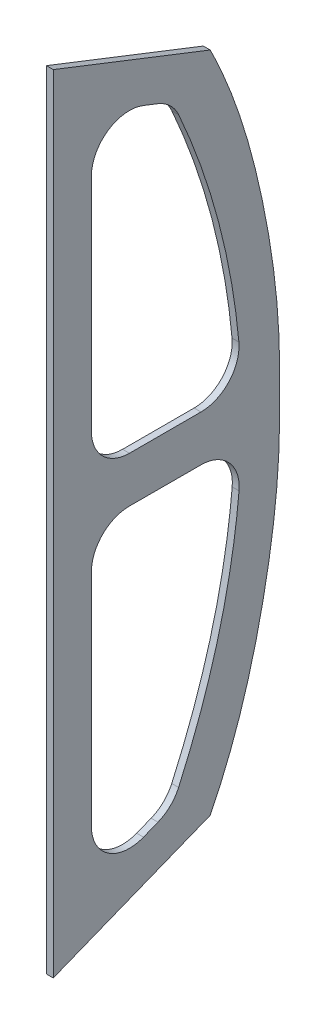
from build123d import *

# Parameters (mm, degrees)
EXTRUDE_4_DEPTH = 9


with BuildPart() as part:
    # Эскиз1 → Бобышка-Вытянуть4 (new body)
    with BuildSketch(Plane(origin=(0, 0, 0), x_dir=(0, 0, -1), z_dir=(1, 0, 0))):
        with BuildLine():
            Line((-455, -516.542644104), (-455, 516.556548518))
            Line((-455, 516.556548518), (-248.999999692, 435.905604479))
            add(Edge.make_bspline(
                [(-248.999999692, 435.905604479), (-244.812182794, 427.580683135), (-236.801363167, 410.73826292), (-222.212406758, 376.463926678), (-206.472110198, 332.573595341), (-191.065214882, 278.622516157), (-178.618404528, 223.741954043), (-168.601235151, 168.376182512), (-162.664180548, 121.995794186), (-159.588454358, 84.78039118), (-158.191016915, 56.847307797), (-157.699086883, 28.820440013), (-157.668208508, 0.657149051), (-157.69908686, -27.506141911), (-158.191016904, -55.533009684), (-159.588454431, -83.466093036), (-162.664180797, -120.681496001), (-168.601235656, -167.061884287), (-178.618405136, -222.427655869), (-191.065215126, -277.308218149), (-206.47210996, -331.259297463), (-222.212406313, -375.149628797), (-236.801362845, -409.423964908), (-244.812182664, -426.266385019), (-248.999999692, -434.591306286)],
                knots=[0.002534483, 0.002534483, 0.002534483, 0.002534483, 0.033626078, 0.064717673, 0.126900862, 0.189084052, 0.251267242, 0.313450431, 0.375633621, 0.406725216, 0.43781681, 0.468908405, 0.5, 0.531091595, 0.56218319, 0.593274784, 0.624366379, 0.686549569, 0.748732758, 0.810915948, 0.873099138, 0.935282327, 0.966373922, 0.997465517, 0.997465517, 0.997465517, 0.997465517], degree=3))
            Line((-248.999999692, -434.591306286), (-455, -516.542644104))
        make_face()
        with BuildLine():
            Line((-405, -369.137843077), (-405, -79.83378018))
            ThreePointArc((-405, -79.83378018), (-390.335381972, -44.458495292), (-354.943568764, -29.833812025))
            Line((-354.943568764, -29.833812025), (-260.787453694, -29.940079012))
            ThreePointArc((-260.787453694, -29.940079012), (-223.891969122, -46.256877511), (-211.052398945, -84.501617445))
            add(Edge.make_bspline(
                [(-211.052398945, -84.501617445), (-216.00272922, -138.536584682), (-234.431884839, -238.848455182), (-270.011454394, -336.792856901), (-290.419546493, -382.113233823)],
                knots=[0.6034229, 0.6034229, 0.6034229, 0.6034229, 0.80171145, 0.97615254, 0.97615254, 0.97615254, 0.97615254], degree=3))
            ThreePointArc((-290.419546493, -382.113233823), (-301.450056693, -397.716221108), (-317.52810706, -408.041997779))
            Line((-317.52810706, -408.041997779), (-336.517727965, -415.596487272))
            ThreePointArc((-336.517727965, -415.596487272), (-383.070325953, -410.514851196), (-405, -369.137843077))
        make_face(mode=Mode.SUBTRACT)
        with BuildLine():
            Line((-336.771752099, 416.573644789), (-317.815177046, 409.151966772))
            ThreePointArc((-317.815177046, 409.151966772), (-301.515585195, 398.756977377), (-290.377663678, 382.955736813))
            add(Edge.make_bspline(
                [(-290.377663678, 382.955736813), (-270.15153544, 337.596182562), (-234.790316493, 239.488359394), (-216.31168023, 139.023424648), (-211.259016819, 84.867467904)],
                knots=[0.024188491, 0.024188491, 0.024188491, 0.024188491, 0.1987169, 0.3974338, 0.3974338, 0.3974338, 0.3974338], degree=3))
            ThreePointArc((-211.259016819, 84.867467904), (-224.0817696, 46.549566009), (-261.042812551, 30.222720063))
            Line((-261.042812551, 30.222720063), (-355, 30.222720063))
            ThreePointArc((-355, 30.222720063), (-390.355339059, 44.867381004), (-405, 80.222720063))
            Line((-405, 80.222720063), (-405, 370.014746838))
            ThreePointArc((-405, 370.014746838), (-383.183218455, 411.314942933), (-336.771752099, 416.573644789))
        make_face(mode=Mode.SUBTRACT)
    extrude(amount=EXTRUDE_4_DEPTH)


solid = part.part
